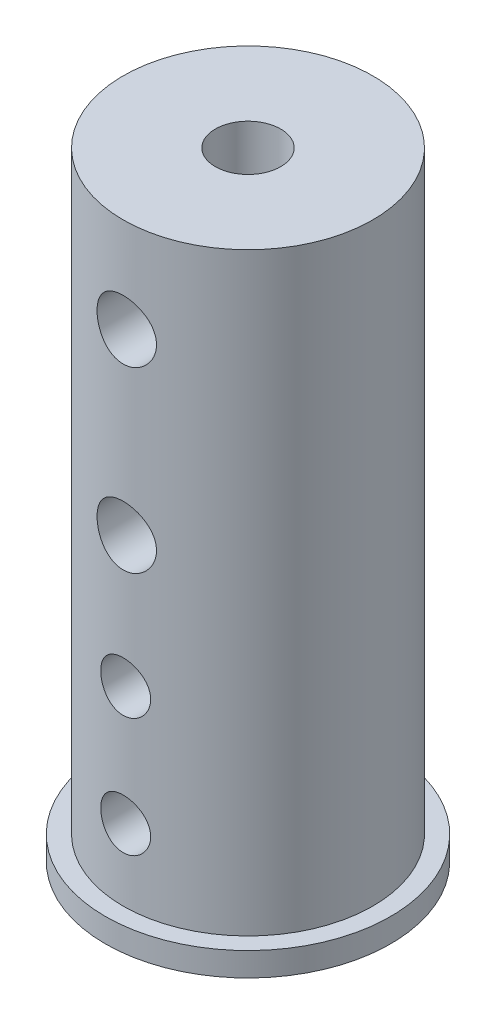
from build123d import *

# Parameters (mm, degrees)
SKETCH_1_R                 = 12
SKETCH_1_R_2               = 2.75
EXTRUDE_1_DEPTH            = 2
SKETCH_2_R                 = 10.5
SKETCH_2_R_2               = 2.75
EXTRUDE_2_DEPTH            = 50
SKETCH_7_W                 = 2.1
SKETCH_7_H                 = 10.5
HOLE_WIZARD_M51_AT_2_COUNT = 2
HOLE_WIZARD_M51_AT_2_PITCH = 10
SKETCH_9_W                 = 2.5
SKETCH_9_H                 = 12
HOLE_WIZARD_M61_AT_2_COUNT = 2
HOLE_WIZARD_M61_AT_2_PITCH = 15


with BuildPart() as part:
    # Эскиз1 → Бобышка-Вытянуть1 (new body)
    with BuildSketch(Plane(origin=(0, 0, 0), x_dir=(1, 0, 0), z_dir=(0, 1, 0))):
        Circle(SKETCH_1_R)
        Circle(SKETCH_1_R_2, mode=Mode.SUBTRACT)
    extrude(amount=EXTRUDE_1_DEPTH)

    # Эскиз2 → Бобышка-Вытянуть2 (add)
    with BuildSketch(Plane(origin=(0, 2, 0), x_dir=(1, 0, 0), z_dir=(0, 1, 0))):
        Circle(SKETCH_2_R)
        Circle(SKETCH_2_R_2, mode=Mode.SUBTRACT)
    extrude(amount=EXTRUDE_2_DEPTH)

    # Эскиз7 → Отверстие обработанное метчиком M51 (revolve, cut)
    with BuildSketch(Plane(origin=(0, 8, 0), x_dir=(0, 1, 0), z_dir=(1, 0, 0))):
        with Locations((1.05, 5.25)):
            Rectangle(SKETCH_7_W, SKETCH_7_H)
    hole_wizard_m51 = revolve(axis=Axis((0, 8, -6.35), (0, 0, 1)), mode=Mode.SUBTRACT)

    # Отверстие обработанное метчиком M51 at 2: Отверстие обработанное метчиком M51 ×2
    with Locations(*[(0, i * HOLE_WIZARD_M51_AT_2_PITCH, 0) for i in range(1, HOLE_WIZARD_M51_AT_2_COUNT)]):
        add(hole_wizard_m51, mode=Mode.SUBTRACT)

    # Эскиз9 → Отверстие обработанное метчиком M61 (revolve, cut)
    with BuildSketch(Plane(origin=(0, 44, 0), x_dir=(0, 1, 0), z_dir=(1, 0, 0))):
        with Locations((1.25, 6)):
            Rectangle(SKETCH_9_W, SKETCH_9_H)
    hole_wizard_m61 = revolve(axis=Axis((0, 44, -6.35), (0, 0, 1)), mode=Mode.SUBTRACT)

    # Отверстие обработанное метчиком M61 at 2: Отверстие обработанное метчиком M61 ×2
    with Locations(*[(0, -i * HOLE_WIZARD_M61_AT_2_PITCH, 0) for i in range(1, HOLE_WIZARD_M61_AT_2_COUNT)]):
        add(hole_wizard_m61, mode=Mode.SUBTRACT)


solid = part.part
